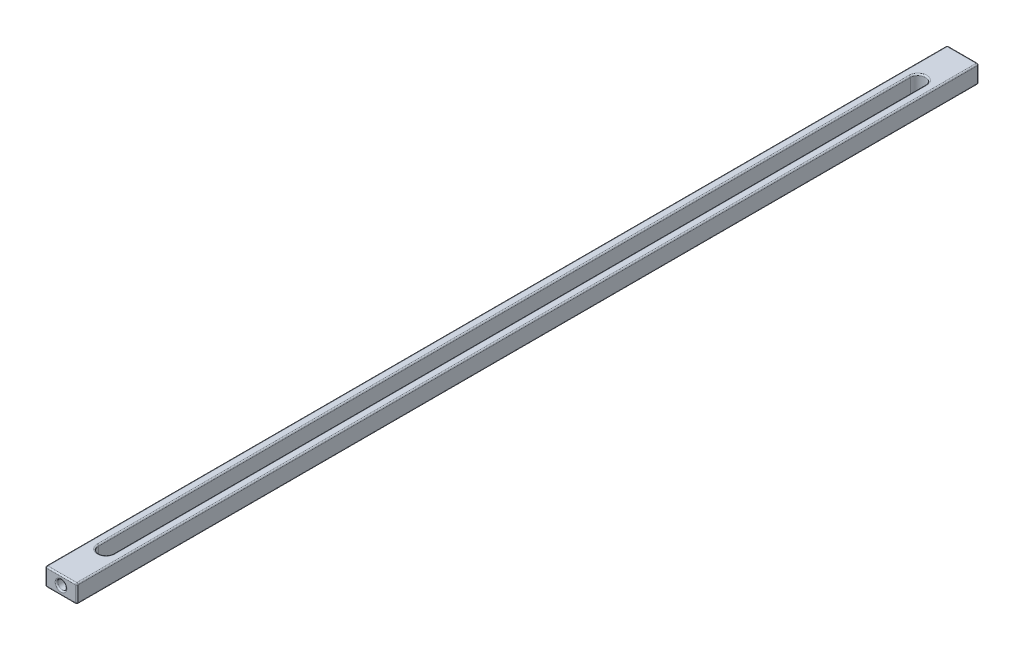
from build123d import *

# Parameters (mm, degrees)
ESQUISSE1_W                         = 7
ESQUISSE1_H                         = 4
BOSS_EXTRU_1_DEPTH                  = 200
ENL_V_MAT_EXTRU_1_DEPTH             = 5
ESQUISSE5_R                         = 1
ENL_V_MAT_EXTRU_3_DEPTH             = 1
ENL_V_MAT_EXTRU_3_DIRECTION_2_REACH = 202
CONG_6_R                            = 0.3


with BuildPart() as part:
    # Esquisse1 → Boss.-Extru.1 (new body)
    with BuildSketch(Plane.XY):
        Rectangle(ESQUISSE1_W, ESQUISSE1_H)
    extrude(amount=BOSS_EXTRU_1_DEPTH)

    # Esquisse2 → Enlèv. mat.-Extru.1 (cut, through all)
    with BuildSketch(Plane(origin=(0, 2, 0), x_dir=(1, 0, 0), z_dir=(0, 1, 0))):
        with BuildLine():
            Line((-1.65, -190), (-1.65, -10))
            ThreePointArc((-1.65, -10), (0, -8.35), (1.65, -10))
            Line((1.65, -10), (1.65, -190))
            ThreePointArc((1.65, -190), (0, -191.65), (-1.65, -190))
        make_face()
    extrude(amount=-ENL_V_MAT_EXTRU_1_DEPTH, mode=Mode.SUBTRACT)

    # Esquisse5 → Enlèv. mat.-Extru.3 (cut)
    with BuildSketch(Plane.XY.offset(200)):
        Circle(ESQUISSE5_R)
    extrude(amount=ENL_V_MAT_EXTRU_3_DEPTH, mode=Mode.SUBTRACT)

    # Esquisse5 → Enlèv. mat.-Extru.3 direction 2 (cut, up to next)
    with BuildSketch(Plane.XY.offset(200), mode=Mode.PRIVATE) as enl_v_mat_extru_3_direction_2_sk1:
        Circle(ESQUISSE5_R)
    enl_v_mat_extru_3_direction_2_tool1 = extrude(enl_v_mat_extru_3_direction_2_sk1.sketch, amount=-ENL_V_MAT_EXTRU_3_DIRECTION_2_REACH, mode=Mode.PRIVATE) & part.part
    add(enl_v_mat_extru_3_direction_2_tool1.solids().sort_by_distance((0, 0, 200))[0], mode=Mode.SUBTRACT)

    # Congé6
    cong_6_edges = [part.edges().sort_by_distance(p)[0] for p in [
        (-3.5, -2, 100),
        (0, -2, 0),
        (0, -2, 200),
        (3.5, -2, 100),
        (0, -2, 191.65),
        (1.65, -2, 100),
        (0, -2, 8.35),
        (-1.65, -2, 100),
        (-3.5, 2, 100),
        (-3.5, 0, 0),
        (-3.5, 0, 200),
        (3.5, 0, 0),
        (0, 2, 0),
        (3.5, 0, 200),
        (0, 2, 200),
        (-1, 0, 200),
        (3.5, 2, 100),
        (0, 2, 191.65),
        (1.65, 2, 100),
        (0, 2, 8.35),
        (-1.65, 2, 100),
    ]]
    fillet(cong_6_edges, radius=CONG_6_R)


solid = part.part
